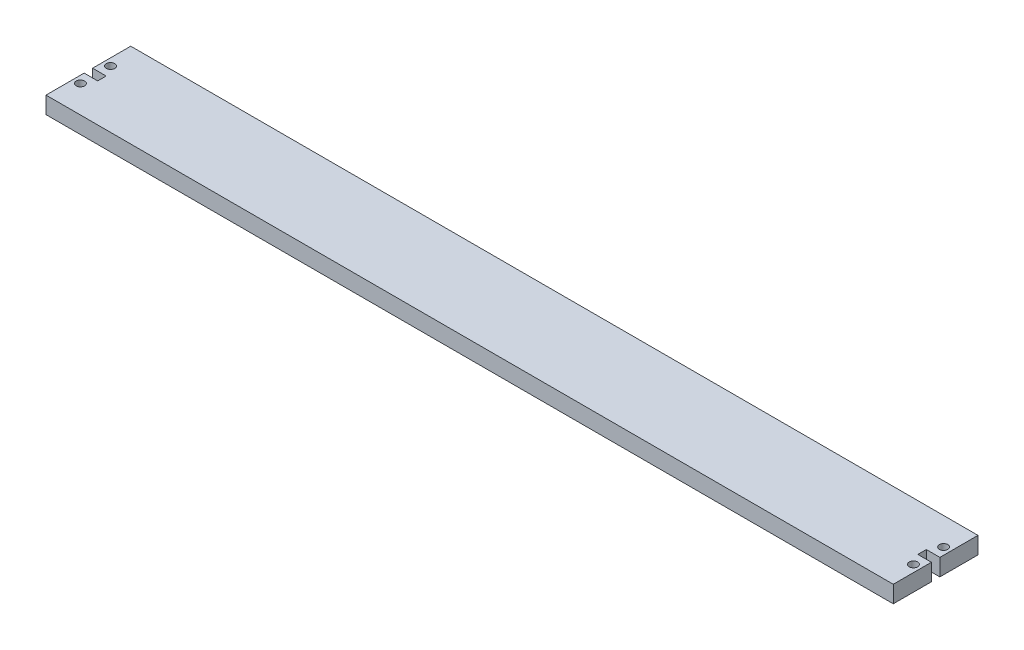
from build123d import *

# Parameters (mm, degrees)
SKETCH1_W           = 500
SKETCH1_H           = 50
BOSS_EXTRUDE1_DEPTH = 10
SKETCH2_R           = 2.5
CUT_EXTRUDE1_DEPTH  = 10


with BuildPart() as part:
    # Sketch1 → Boss-Extrude1 (new body)
    with BuildSketch(Plane(origin=(0, 0, 0), x_dir=(1, 0, 0), z_dir=(0, 1, 0))):
        with Locations((250, -25)):
            Rectangle(SKETCH1_W, SKETCH1_H)
    extrude(amount=BOSS_EXTRUDE1_DEPTH)

    # Sketch2 → Cut-Extrude1 (cut)
    with BuildSketch(Plane(origin=(0, 10, 0), x_dir=(1, 0, 0), z_dir=(0, 1, 0))):
        with Locations((4.2, -16.1)):
            Circle(SKETCH2_R)
        with Locations((4.2, -33.9)):
            Circle(SKETCH2_R)
        with Locations((495.8, -33.9)):
            Circle(SKETCH2_R)
        with Locations((495.8, -16.1)):
            Circle(SKETCH2_R)
        Polygon((0, -25), (0, -22.5), (8, -22.5), (8, -27.5), (0, -27.5), align=None)
        Polygon((500, -27.5), (500, -25), (500, -22.5), (492, -22.5), (492, -27.5), align=None)
    extrude(amount=-CUT_EXTRUDE1_DEPTH, mode=Mode.SUBTRACT)


solid = part.part
